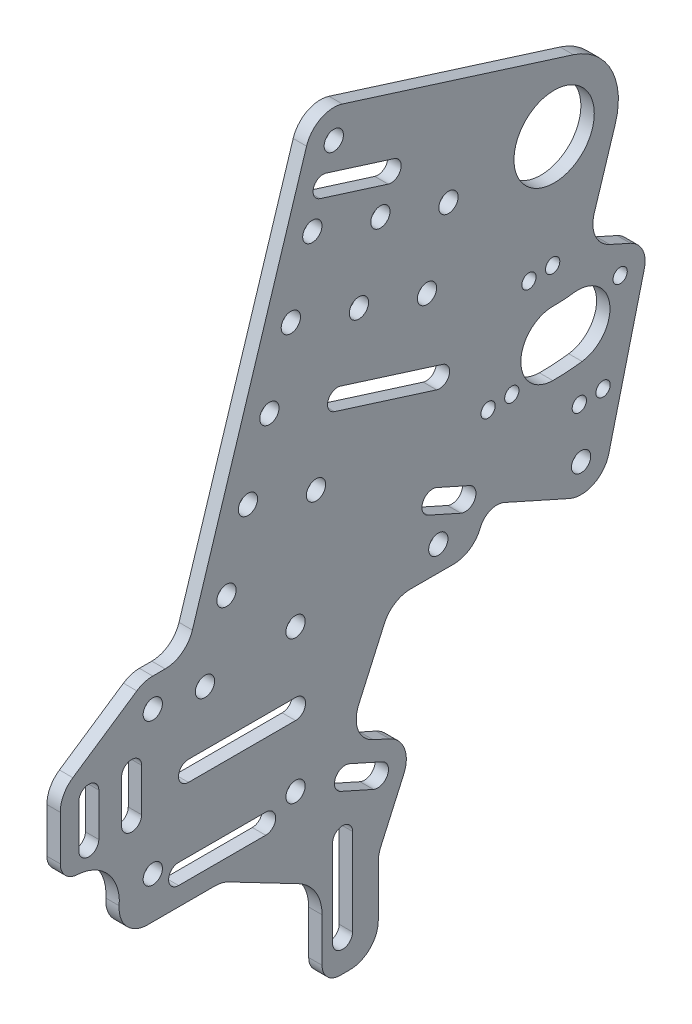
from build123d import *

# Parameters (mm, degrees)
SKETCH2_R           = 14.2875
SKETCH2_R_2         = 3.429
SKETCH2_R_3         = 2.54
BOSS_EXTRUDE1_DEPTH = 4.7625


with BuildPart() as part:
    # Sketch2 → Boss-Extrude1 (new body)
    with BuildSketch(Plane(origin=(0, 0, 0), x_dir=(0, 0, -1), z_dir=(1, 0, 0))):
        with BuildLine():
            Line((38.021448917, 246.234864084), (120.241230069, 220.311066665))
            ThreePointArc((120.241230069, 220.311066665), (133.644163138, 209.06467047), (135.169064986, 191.634962595))
            Line((135.169064986, 191.634962595), (127.622152065, 167.6992128))
            ThreePointArc((127.622152065, 167.6992128), (128.044603019, 160.47960856), (133.162508812, 155.36999111))
            Line((133.162508812, 155.36999111), (140.48887895, 152.092017357))
            ThreePointArc((140.48887895, 152.092017357), (144.852236282, 147.866521475), (145.483799346, 141.825426314))
            Line((145.483799346, 141.825426314), (132.821367632, 91.06703794))
            ThreePointArc((132.821367632, 91.06703794), (127.408392323, 84.390132513), (118.814072234, 84.252183312))
            Line((118.814072234, 84.252183312), (95.644233558, 94.61886171))
            ThreePointArc((95.644233558, 94.61886171), (90.786060122, 94.754966448), (87.254572158, 91.415959651))
            Line((87.254572158, 91.415959651), (86.910445683, 90.646826606))
            ThreePointArc((86.910445683, 90.646826606), (83.162135594, 86.27028604), (77.636394916, 84.636234079))
            Line((77.636394916, 84.636234079), (62.21871433, 84.636234079))
            ThreePointArc((62.21871433, 84.636234079), (56.692973652, 83.002182118), (52.944663563, 78.625641552))
            Line((52.944663563, 78.625641552), (43.839685496, 58.275741142))
            ThreePointArc((43.839685496, 58.275741142), (43.621917914, 50.502663645), (48.96432879, 44.852282903))
            Line((48.96432879, 44.852282903), (54.760610519, 42.258903232))
            ThreePointArc((54.760610519, 42.258903232), (60.103021394, 36.60852249), (59.885253813, 28.835444993))
            Line((59.885253813, 28.835444993), (51.685949233, 10.509752126))
            ThreePointArc((51.685949233, 10.509752126), (51.023955621, 8.481811623), (50.8, 6.360344653))
            Line((50.8, 6.360344653), (50.8, -11.7475))
            ThreePointArc((50.8, -11.7475), (47.824204897, -18.931704897), (40.64, -21.9075))
            Line((40.64, -21.9075), (37.1475, -21.9075))
            ThreePointArc((37.1475, -21.9075), (32.657371939, -20.047628061), (30.7975, -15.5575))
            Line((30.7975, -15.5575), (30.7975, 0))
            ThreePointArc((30.7975, 0), (28.552596998, 8.032774411), (22.468409419, 13.737834946))
            Line((22.468409419, 13.737834946), (-2.554479623, 26.788416358))
            ThreePointArc((-2.554479623, 26.788416358), (-4.834094275, 27.647905305), (-7.252780881, 27.94))
            Line((-7.252780881, 27.94), (-31.256978796, 27.94))
            ThreePointArc((-31.256978796, 27.94), (-38.707276299, 31.19213006), (-41.38801938, 38.866561592))
            ThreePointArc((-41.38801938, 38.866561592), (-45.28789684, 50.537792221), (-56.355984579, 55.915905494))
            ThreePointArc((-56.355984579, 55.915905494), (-60.621662669, 57.889989399), (-62.361270294, 62.25654206))
            Line((-62.361270294, 62.25654206), (-62.361270294, 78.164314079))
            ThreePointArc((-62.361270294, 78.164314079), (-61.17251471, 82.933210558), (-57.884425091, 86.586151856))
            Line((-57.884425091, 86.586151856), (-35.119675091, 101.948071856))
            ThreePointArc((-35.119675091, 101.948071856), (-32.408029017, 103.24198088), (-29.436520294, 103.686234079))
            Line((-29.436520294, 103.686234079), (-25.026637608, 103.686234079))
            ThreePointArc((-25.026637608, 103.686234079), (-19.01893158, 105.6527569), (-15.336873388, 110.791063156))
            Line((-15.336873388, 110.791063156), (25.276513775, 239.600270788))
            ThreePointArc((25.276513775, 239.600270788), (30.274912084, 245.55712993), (38.021448917, 246.234864084))
        make_face()
        with Locations((113.367095492, 198.509097171)):
            Circle(SKETCH2_R, mode=Mode.SUBTRACT)
        with Locations((-29.436520294, 42.726234079)):
            Circle(SKETCH2_R_2, mode=Mode.SUBTRACT)
        with Locations((21.363479706, 93.526234079)):
            Circle(SKETCH2_R_2, mode=Mode.SUBTRACT)
        with Locations((122.963479706, 93.526234079)):
            Circle(SKETCH2_R_2, mode=Mode.SUBTRACT)
        with Locations((104.398969727, 158.50014909)):
            Circle(SKETCH2_R_3, mode=Mode.SUBTRACT)
        with Locations((136.858147411, 143.977222936)):
            Circle(SKETCH2_R_3, mode=Mode.SUBTRACT)
        with Locations((122.335221257, 111.518045252)):
            Circle(SKETCH2_R_3, mode=Mode.SUBTRACT)
        with Locations((89.876043573, 126.040971407)):
            Circle(SKETCH2_R_3, mode=Mode.SUBTRACT)
        with Locations((112.840572264, 159.063757816)):
            Circle(SKETCH2_R_3, mode=Mode.SUBTRACT)
        with Locations((130.776823793, 112.081653978)):
            Circle(SKETCH2_R_3, mode=Mode.SUBTRACT)
        with Locations((98.317646109, 126.604580132)):
            Circle(SKETCH2_R_3, mode=Mode.SUBTRACT)
        with Locations((-29.436520294, 93.526234079)):
            Circle(SKETCH2_R_2, mode=Mode.SUBTRACT)
        with Locations((21.363479706, 42.726234079)):
            Circle(SKETCH2_R_2, mode=Mode.SUBTRACT)
        with Locations((72.163479706, 93.526234079)):
            Circle(SKETCH2_R_2, mode=Mode.SUBTRACT)
        with Locations((34.966277994, 236.545099865)):
            Circle(SKETCH2_R_2, mode=Mode.SUBTRACT)
        with Locations((27.328350687, 212.320689316)):
            Circle(SKETCH2_R_2, mode=Mode.SUBTRACT)
        with Locations((19.690423379, 188.096278767)):
            Circle(SKETCH2_R_2, mode=Mode.SUBTRACT)
        with Locations((12.052496072, 163.871868218)):
            Circle(SKETCH2_R_2, mode=Mode.SUBTRACT)
        with Locations((4.414568765, 139.647457669)):
            Circle(SKETCH2_R_2, mode=Mode.SUBTRACT)
        with Locations((-3.223358543, 115.42304712)):
            Circle(SKETCH2_R_2, mode=Mode.SUBTRACT)
        with Locations((-10.86128585, 91.198636571)):
            Circle(SKETCH2_R_2, mode=Mode.SUBTRACT)
        with Locations((51.552761236, 204.682762008)):
            Circle(SKETCH2_R_2, mode=Mode.SUBTRACT)
        with Locations((43.914833928, 180.458351459)):
            Circle(SKETCH2_R_2, mode=Mode.SUBTRACT)
        with Locations((75.777171785, 197.044834701)):
            Circle(SKETCH2_R_2, mode=Mode.SUBTRACT)
        with Locations((68.139244477, 172.820424152)):
            Circle(SKETCH2_R_2, mode=Mode.SUBTRACT)
        with Locations((28.638979314, 132.009530361)):
            Circle(SKETCH2_R_2, mode=Mode.SUBTRACT)
        with BuildLine():
            Line((30.078004517, 221.041477113), (54.302415066, 213.403549806))
            ThreePointArc((54.302415066, 213.403549806), (58.763142366, 215.72565746), (56.441034713, 220.18638476))
            Line((56.441034713, 220.18638476), (32.216624164, 227.824312067))
            ThreePointArc((32.216624164, 227.824312067), (27.755896864, 225.502204413), (30.078004517, 221.041477113))
        make_face(mode=Mode.SUBTRACT)
        with BuildLine():
            Line((41.656, 20.2565), (41.656, -10.7315))
            ThreePointArc((41.656, -10.7315), (38.1, -14.2875), (34.544, -10.7315))
            Line((34.544, -10.7315), (34.544, 20.2565))
            ThreePointArc((34.544, 20.2565), (38.1, 23.8125), (41.656, 20.2565))
        make_face(mode=Mode.SUBTRACT)
        with BuildLine():
            Line((-20.2565, 41.656), (10.7315, 41.656))
            ThreePointArc((10.7315, 41.656), (14.2875, 38.1), (10.7315, 34.544))
            Line((10.7315, 34.544), (-20.2565, 34.544))
            ThreePointArc((-20.2565, 34.544), (-23.8125, 38.1), (-20.2565, 41.656))
        make_face(mode=Mode.SUBTRACT)
        with BuildLine():
            Line((-48.645270294, 78.164314079), (-48.645270294, 62.924314079))
            ThreePointArc((-48.645270294, 62.924314079), (-52.201270294, 59.368314079), (-55.757270294, 62.924314079))
            Line((-55.757270294, 62.924314079), (-55.757270294, 78.164314079))
            ThreePointArc((-55.757270294, 78.164314079), (-52.201270294, 81.720314079), (-48.645270294, 78.164314079))
        make_face(mode=Mode.SUBTRACT)
        with BuildLine():
            Line((-33.405270294, 78.164314079), (-33.405270294, 62.924314079))
            ThreePointArc((-33.405270294, 62.924314079), (-36.961270294, 59.368314079), (-40.517270294, 62.924314079))
            Line((-40.517270294, 62.924314079), (-40.517270294, 78.164314079))
            ThreePointArc((-40.517270294, 78.164314079), (-36.961270294, 81.720314079), (-33.405270294, 78.164314079))
        make_face(mode=Mode.SUBTRACT)
        with BuildLine():
            Line((37.346216444, 159.625358387), (73.682832268, 148.168467426))
            ThreePointArc((73.682832268, 148.168467426), (76.004939921, 143.707740126), (71.544212621, 141.385632472))
            Line((71.544212621, 141.385632472), (35.207596798, 152.842523433))
            ThreePointArc((35.207596798, 152.842523433), (32.885489144, 157.303250733), (37.346216444, 159.625358387))
        make_face(mode=Mode.SUBTRACT)
        with BuildLine():
            Line((-16.736520294, 71.682234079), (21.363479706, 71.682234079))
            ThreePointArc((21.363479706, 71.682234079), (24.919479706, 68.126234079), (21.363479706, 64.570234079))
            Line((21.363479706, 64.570234079), (-16.736520294, 64.570234079))
            ThreePointArc((-16.736520294, 64.570234079), (-20.292520294, 68.126234079), (-16.736520294, 71.682234079))
        make_face(mode=Mode.SUBTRACT)
        with BuildLine():
            Line((71.695223435, 111.204761595), (83.287786894, 106.018002254))
            ThreePointArc((83.287786894, 106.018002254), (85.209528129, 100.984205414), (80.175731289, 99.062464179))
            Line((80.175731289, 99.062464179), (68.583167831, 104.24922352))
            ThreePointArc((68.583167831, 104.24922352), (66.661426596, 109.28302036), (71.695223435, 111.204761595))
        make_face(mode=Mode.SUBTRACT)
        with BuildLine():
            Line((40.57466739, 41.649380844), (52.167230848, 36.462621503))
            ThreePointArc((52.167230848, 36.462621503), (54.088972084, 31.428824663), (49.055175244, 29.507083428))
            Line((49.055175244, 29.507083428), (37.462611785, 34.693842769))
            ThreePointArc((37.462611785, 34.693842769), (35.54087055, 39.727639609), (40.57466739, 41.649380844))
        make_face(mode=Mode.SUBTRACT)
        with BuildLine():
            ThreePointArc((112.879749334, 123.580682042), (118.115569936, 123.729709032), (123.328186485, 124.244155468))
            ThreePointArc((123.328186485, 124.244155468), (133.137248458, 137.092194354), (120.289209572, 146.901256326))
            ThreePointArc((120.289209572, 146.901256326), (116.666882818, 146.543759651), (113.028431213, 146.440198522))
            ThreePointArc((113.028431213, 146.440198522), (101.524332034, 135.084781222), (112.879749334, 123.580682042))
        make_face(mode=Mode.SUBTRACT)
    extrude(amount=BOSS_EXTRUDE1_DEPTH)


solid = part.part
